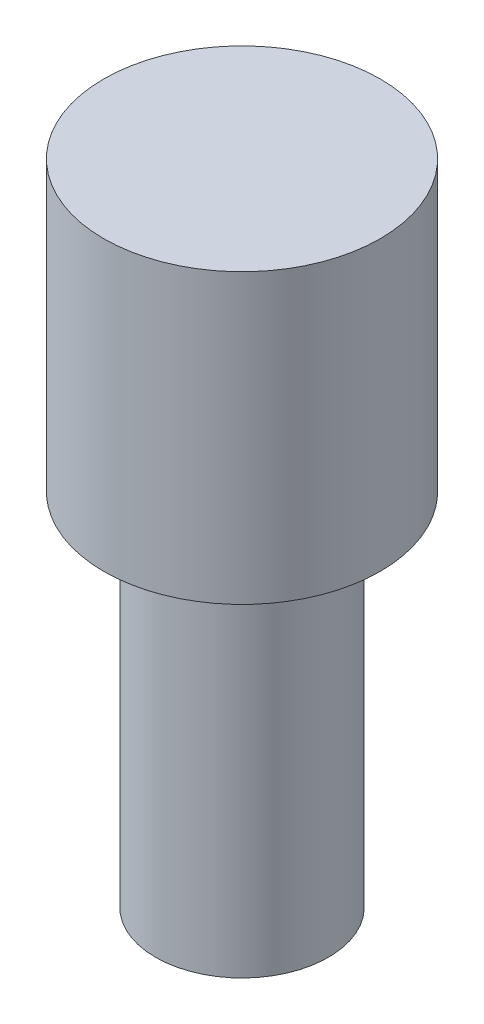
from build123d import *


with BuildPart() as part:
    # Sketch1 → Revolve1 (revolve)
    with BuildSketch(Plane(origin=(0, 0, 0), x_dir=(0, 0, -1), z_dir=(1, 0, 0)), mode=Mode.PRIVATE) as revolve1_sk:
        Polygon((0.762, 0), (0.762, -3.175), (0, -3.175), (0, 2.54), (1.2192, 2.54), (1.2192, 0), align=None)
    revolve(revolve1_sk.sketch.rotate(Axis((0, 53.778641766, 0), (0, -1, 0)), 180), axis=Axis((0, 53.778641766, 0), (0, -1, 0)))  # turned: the seam where the file's is


solid = part.part
